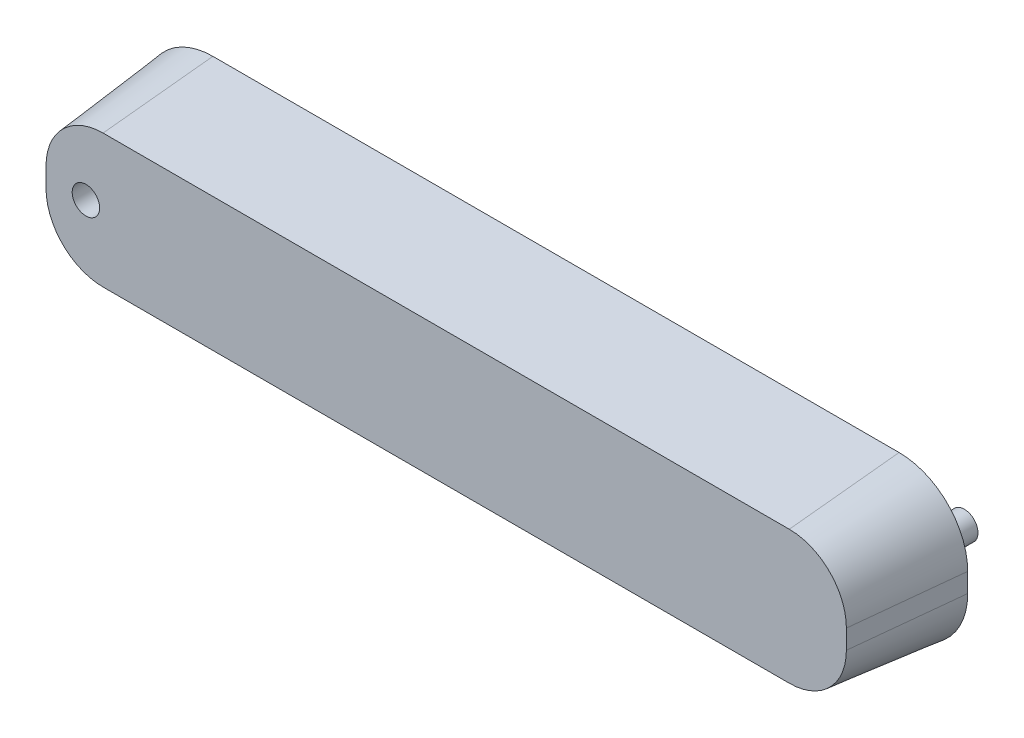
from build123d import *

# Parameters (mm, degrees)
BOSS_EXTRUDE1_DEPTH   = 80
BOSS_EXTRUDE1_TAPER   = 6
SKETCH2_R             = 10
BOSS_EXTRUDE2_DEPTH   = 35
SKETCH3_R             = 10
CUT_EXTRUDE1_DEPTH    = 30
BODY_MOVE_COPY2_ANGLE = 90


with BuildPart() as part:
    # Sketch1 → Boss-Extrude1 (new body)
    with BuildSketch(Plane(origin=(0, 0, 0), x_dir=(1, 0, 0), z_dir=(0, 1, 0))):
        with BuildLine():
            ThreePointArc((-250, 57), (-285.355339059, 42.355339059), (-300, 7))
            Line((-300, 7), (-300, -7))
            ThreePointArc((-300, -7), (-285.355339059, -42.355339059), (-250, -57))
            Line((-250, -57), (250, -57))
            ThreePointArc((250, -57), (285.355339059, -42.355339059), (300, -7))
            Line((300, -7), (300, 7))
            ThreePointArc((300, 7), (285.355339059, 42.355339059), (250, 57))
            Line((250, 57), (-250, 57))
        make_face()
    extrude(amount=BOSS_EXTRUDE1_DEPTH, taper=BOSS_EXTRUDE1_TAPER)

    # Sketch2 → Boss-Extrude2 (add)
    with BuildSketch(Plane.XZ):
        with Locations((262.5, 0)):
            Circle(SKETCH2_R)
    extrude(amount=BOSS_EXTRUDE2_DEPTH)

    # Sketch3 → Cut-Extrude1 (cut)
    with BuildSketch(Plane(origin=(0, 80, 0), x_dir=(1, 0, 0), z_dir=(0, 1, 0))):
        with Locations((-262.5, 0)):
            Circle(SKETCH3_R)
    extrude(amount=-CUT_EXTRUDE1_DEPTH, mode=Mode.SUBTRACT)


with BuildPart() as part_1:
    # Body-Move/Copy1: moved
    add(part.part.moved(Location((262.5, 0, 0))))


with BuildPart() as part_2:
    # Body-Move/Copy2: moved
    add(part_1.part.rotate(Axis((0, 0, 0), (1, 0, 0)), BODY_MOVE_COPY2_ANGLE))


solid = part_2.part
